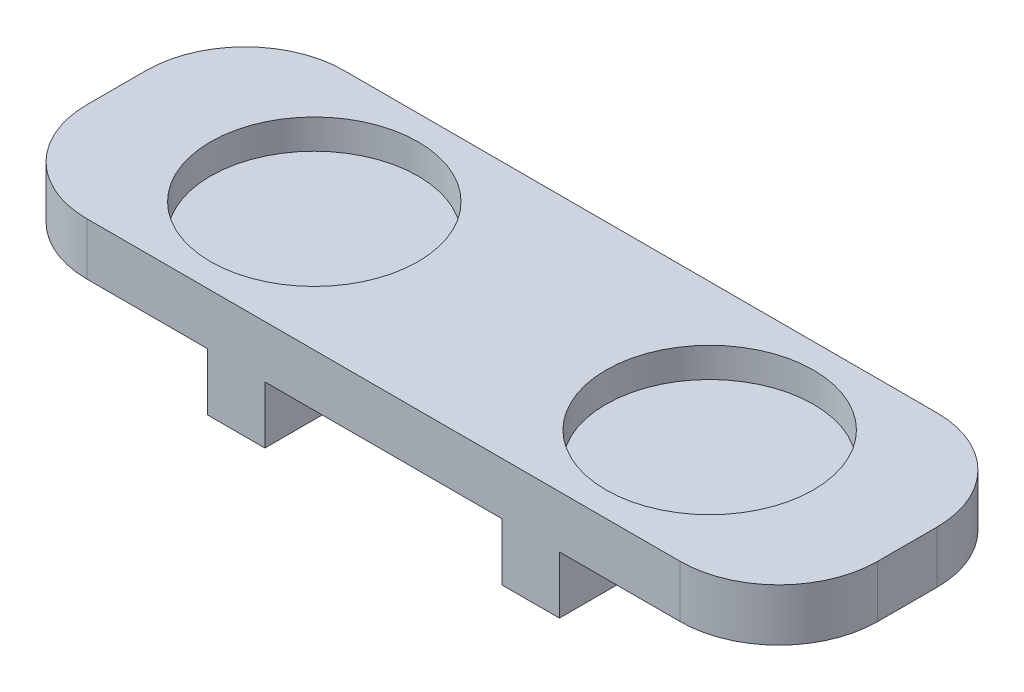
from build123d import *

# Parameters (mm, degrees)
SKETCH1_W           = 7.366
SKETCH1_H           = 7.366
BOSS_EXTRUDE1_DEPTH = 33.02
SKETCH2_R           = 13.335
CUT_EXTRUDE1_DEPTH  = 3.81
FILLET1_R           = 12.7


with BuildPart() as part:
    # Sketch1 → Boss-Extrude1 (new body)
    with BuildSketch(Plane.XY):
        Polygon((48.76226865, 0), (41.39626865, 0), (13.20226865, 0), (13.20226865, 6.709268486), (114.80226865, 6.709268486), (114.80226865, 0), (86.60826865, 0), (79.24226865, 0), align=None)
        with Locations((45.07926865, -3.683)):
            Rectangle(SKETCH1_W, SKETCH1_H)
        with Locations((82.92526865, -3.683)):
            Rectangle(SKETCH1_W, SKETCH1_H)
    extrude(amount=BOSS_EXTRUDE1_DEPTH)

    # Sketch2 → Cut-Extrude1 (cut)
    with BuildSketch(Plane(origin=(0, 6.709268486, 0), x_dir=(1, 0, 0), z_dir=(0, 1, 0))):
        with Locations((38.60226865, -16.51)):
            Circle(SKETCH2_R)
        with Locations((89.40226865, -16.51)):
            Circle(SKETCH2_R)
    extrude(amount=-CUT_EXTRUDE1_DEPTH, mode=Mode.SUBTRACT)

    # Fillet1
    fillet1_edges = [part.edges().sort_by_distance(p)[0] for p in [
        (114.80226865, 3.354634243, 33.02),
        (13.20226865, 3.354634243, 0),
        (114.80226865, 3.354634243, 0),
        (13.20226865, 3.354634243, 33.02),
    ]]
    fillet(fillet1_edges, radius=FILLET1_R)


solid = part.part
